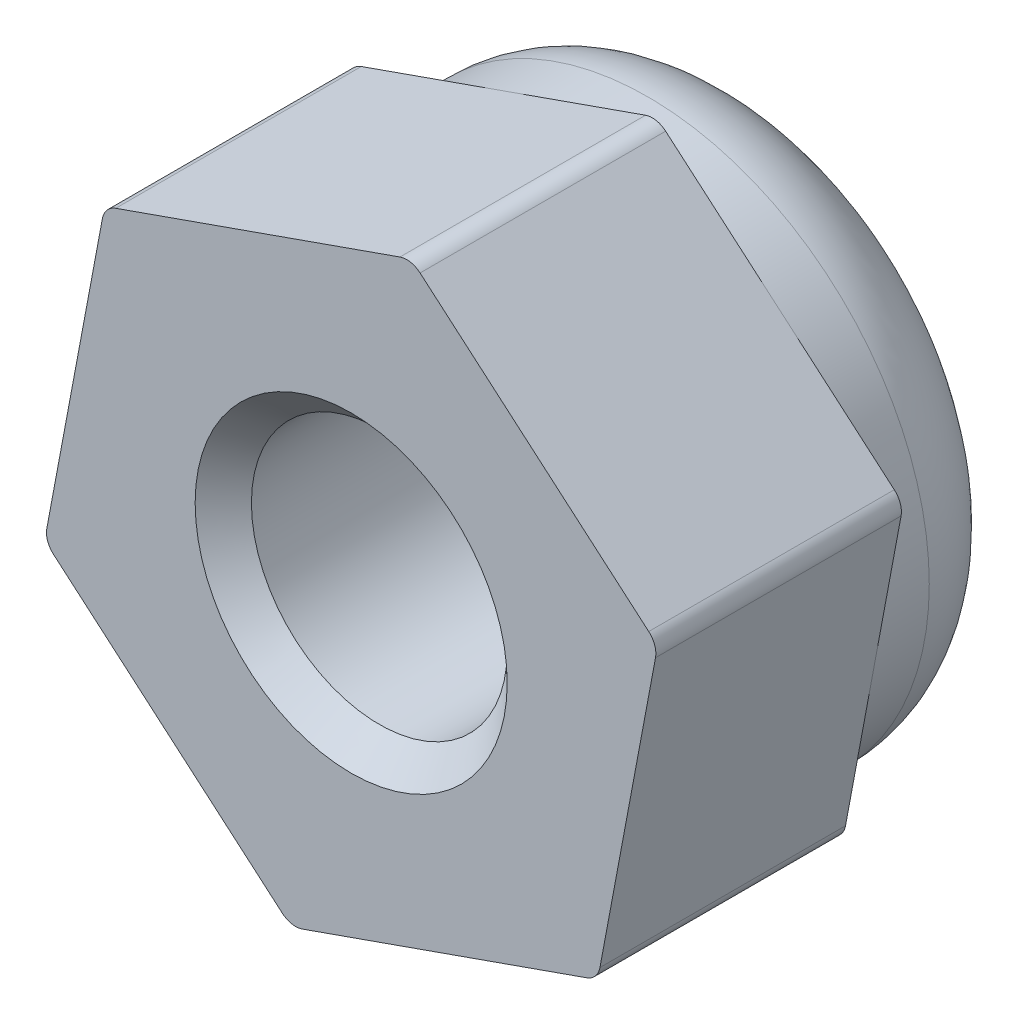
from build123d import *

# Parameters (mm, degrees)
EXTRUDE_1_DEPTH              = 2.4
SKETCH_2_R                   = 2.75
EXTRUDE_3_DEPTH              = 3.9
FILLET_1_R                   = 1
FILLET_2_R                   = 0.2
HOLE_WIZARD_M3_1_D           = 2.5
HOLE_WIZARD_M3_1_DEPTH       = 7.5
HOLE_WIZARD_M3_1_CSINK_D     = 3.05
HOLE_WIZARD_M3_1_CSINK_ANGLE = 90
HOLE_WIZARD_M3_1_TIP         = 0.751075774


with BuildPart() as part:
    # 草图1 → 凸台-拉伸1 (new body)
    with BuildSketch(Plane.XY):
        Polygon((2.409913138, -2.067764977), (2.995693568, 1.05316351), (0.58578043, 3.120928487), (-2.409913138, 2.067764977), (-2.995693568, -1.05316351), (-0.58578043, -3.120928487), align=None)
    extrude(amount=EXTRUDE_1_DEPTH)

    # 草图2 → 凸台-拉伸3 (add)
    with BuildSketch(Plane.XY.offset(2.4)):
        Circle(SKETCH_2_R)
    extrude(amount=-EXTRUDE_3_DEPTH)

    # 圆角1
    fillet_1_edges = [part.edges().sort_by_distance(p)[0] for p in [
        (-2.75, 0, -1.5),
    ]]
    fillet(fillet_1_edges, radius=FILLET_1_R)

    # 圆角2
    fillet_2_edges = [part.edges().sort_by_distance(p)[0] for p in [
        (-0.58578043, -3.120928487, 1.2),
        (-2.995693568, -1.05316351, 1.2),
        (-2.409913138, 2.067764977, 1.2),
        (0.58578043, 3.120928487, 1.2),
        (2.995693568, 1.05316351, 1.2),
        (2.409913138, -2.067764977, 1.2),
    ]]
    fillet(fillet_2_edges, radius=FILLET_2_R)

    # M3 螺纹孔1
    with Locations(Plane.XY.offset(2.4)):
        with Locations((0, 0)):
            CounterSinkHole(HOLE_WIZARD_M3_1_D / 2, HOLE_WIZARD_M3_1_CSINK_D / 2, depth=HOLE_WIZARD_M3_1_DEPTH, counter_sink_angle=HOLE_WIZARD_M3_1_CSINK_ANGLE)
            with Locations((0, 0, -(HOLE_WIZARD_M3_1_DEPTH + HOLE_WIZARD_M3_1_TIP / 2))):  # 118° drill point
                Cone(0, HOLE_WIZARD_M3_1_D / 2, HOLE_WIZARD_M3_1_TIP, mode=Mode.SUBTRACT)


solid = part.part
